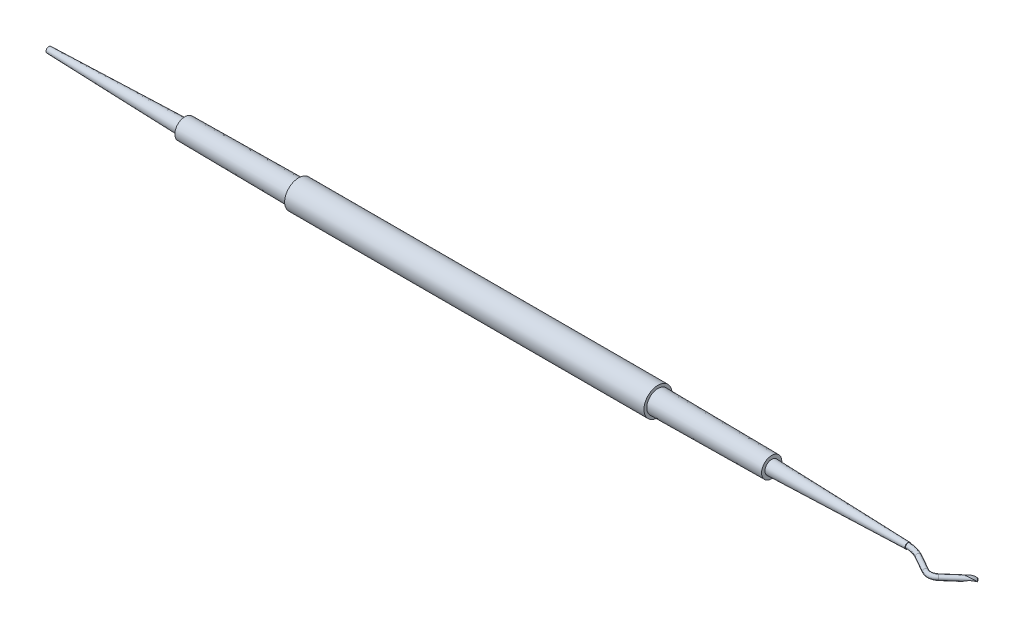
from build123d import *

# Parameters (mm, degrees)
SKETCH2_R          = 0.425
CUT_EXTRUDE2_DEPTH = 10


with BuildPart() as part:
    # Sweep4: sweep along a path in Sketch4
    with BuildLine(Plane(origin=(0, 0, 0), x_dir=(1, 0, 0), z_dir=(0, 1, 0))) as sweep4_path:
        Line((67.536722789, 33.517901337), (63.696993057, 30.160880485))
        ThreePointArc((63.696993057, 30.160880485), (62.67844941, 29.718218887), (61.591563938, 29.94638641))
        Line((61.591563938, 29.94638641), (58.647554869, 31.613971966))
        ThreePointArc((58.647554869, 31.613971966), (57.417647247, 32.11454889), (56.100779486, 32.285163408))
    # Sketch2 → Sweep4 (sweep)
    with BuildSketch(Plane(origin=(50.527312063, 4.259e-06, -50.527312063), x_dir=(0.707106781, 0, 0.707106781), z_dir=(0.707106781, 6e-08, -0.707106781))):
        with Locations((24.054939337, 4.259e-06)):
            Circle(SKETCH2_R)
    sweep(path=sweep4_path.line)

    # Sketch6 → Revolve1 (revolve)
    with BuildSketch(Plane(origin=(0, 0, 0), x_dir=(1, 0, 0), z_dir=(0, 1, 0))):
        Polygon((56.100779486, 32.285163408), (31.850231497, 32.285163408), (11.591647887, 32.285163408), (-52.408352113, 32.285163408), (-72.666935722, 32.285163408), (-96.917483711, 32.285163408), (-96.917483711, 31.785163408), (-72.666935722, 31.085163408), (-72.666935722, 30.485163408), (-52.408352113, 30.285163408), (-52.408352113, 29.785163408), (11.591647887, 29.785163408), (11.591647887, 30.285163408), (31.850231497, 30.485163408), (31.850231497, 31.085163408), (56.100779486, 31.785163408), align=None)
    revolve(axis=Axis((11.591647887, 0, -32.285163408), (-1, 0, 0)))

    # Sketch7 → Cut-Extrude2 (cut)
    with BuildSketch(Plane(origin=(12.979011819, 0, 14.845274956), x_dir=(-0.752843126, 0, 0.65819999), z_dir=(-0.65819999, 0, -0.752843126))):
        with BuildLine():
            Line((-70.90689286, -0.258658753), (-70.424884302, -0.480296071))
            Line((-70.424884302, -0.480296071), (-73.177134487, -0.809094289))
            Line((-73.177134487, -0.809094289), (-73.643040117, 0.425))
            Line((-73.643040117, 0.425), (-71.097248445, 0.425))
            ThreePointArc((-71.097248445, 0.425), (-71.956470511, 0.264804948), (-72.71646768, -0.166853846))
            Line((-72.71646768, -0.166853846), (-72.763912994, -0.258658753))
            ThreePointArc((-72.763912994, -0.258658753), (-71.835402927, -0.055413386), (-70.90689286, -0.258658753))
        make_face()
    extrude(amount=CUT_EXTRUDE2_DEPTH, mode=Mode.SUBTRACT)


solid = part.part
